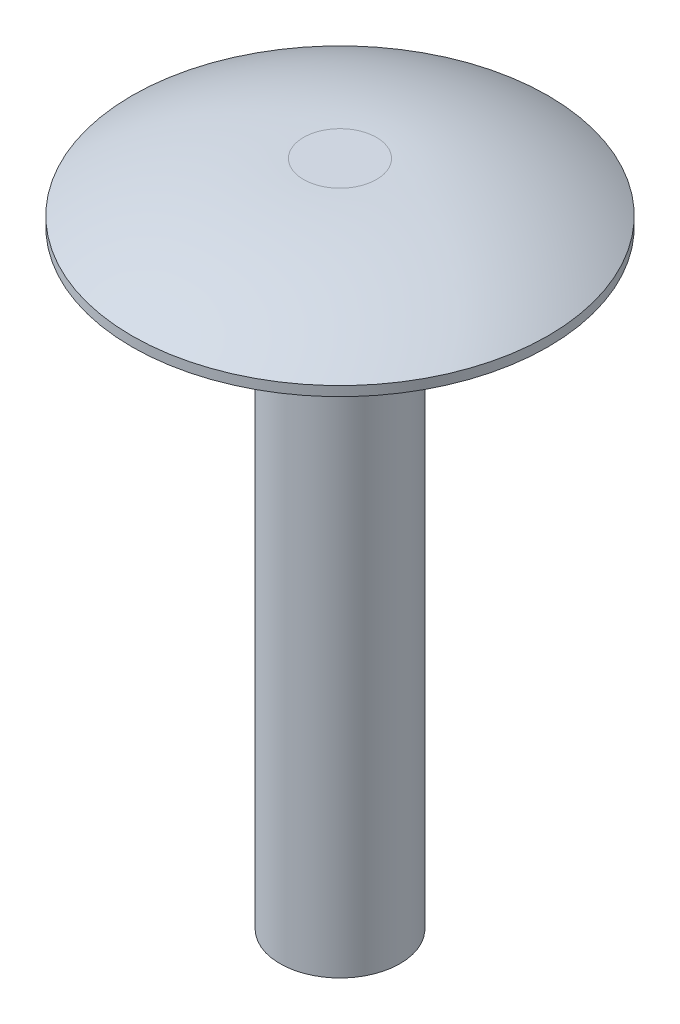
from build123d import *


with BuildPart() as part:
    # Sketch1 → Revolve1 (revolve)
    with BuildSketch(Plane.XY):
        with BuildLine():
            Line((-1.4478, 26.4795), (0, 26.4795))
            Line((0, 26.4795), (0, 0))
            Line((0, 0), (-2.38125, 0))
            Line((-2.38125, 0), (-2.38125, 24.13))
            Line((-2.38125, 24.13), (-8.255, 24.13))
            Line((-8.255, 24.13), (-8.255, 24.511))
            ThreePointArc((-8.255, 24.511), (-4.990855323, 25.977495504), (-1.4478, 26.4795))
        make_face()
    revolve(axis=Axis((0, 0, 0), (0, 1, 0)))


solid = part.part
